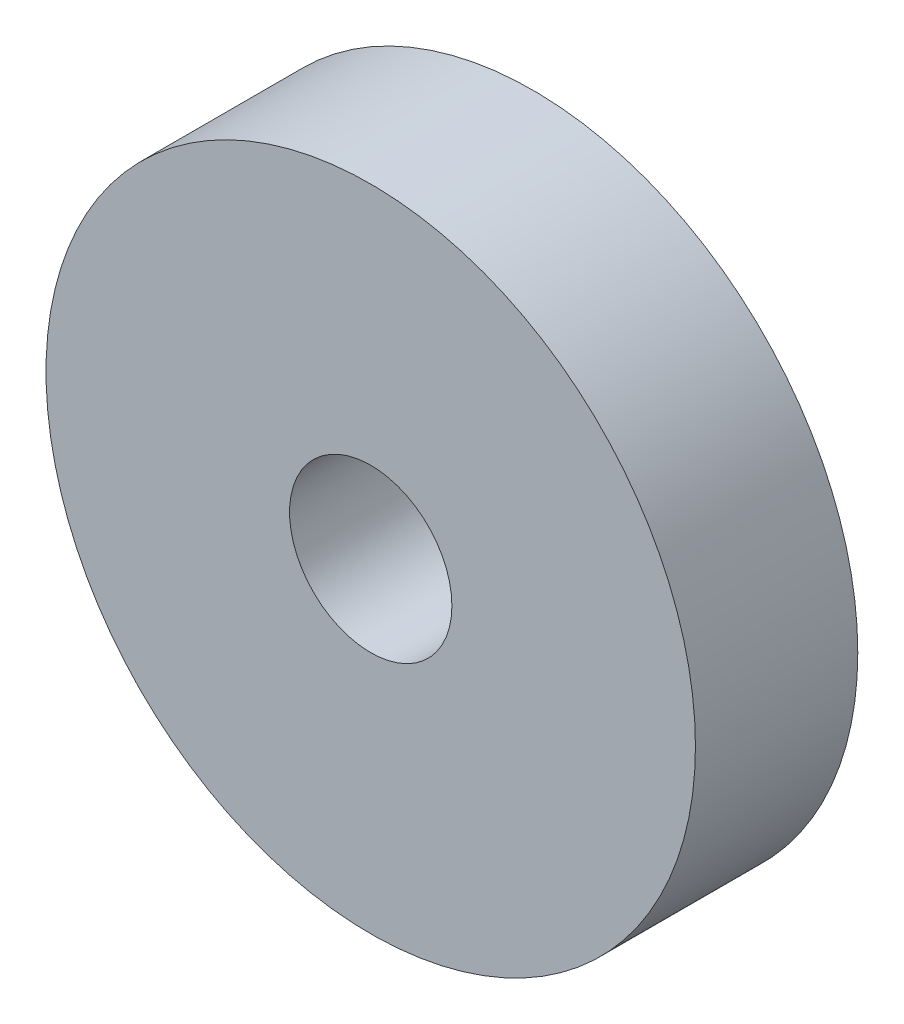
from build123d import *

# Parameters (mm, degrees)
SKETCH1_R           = 6
SKETCH1_R_2         = 1.5
BOSS_EXTRUDE1_DEPTH = 3


with BuildPart() as part:
    # Sketch1 → Boss-Extrude1 (new body)
    with BuildSketch(Plane.XY):
        Circle(SKETCH1_R)
        Circle(SKETCH1_R_2, mode=Mode.SUBTRACT)
    extrude(amount=BOSS_EXTRUDE1_DEPTH)


solid = part.part
